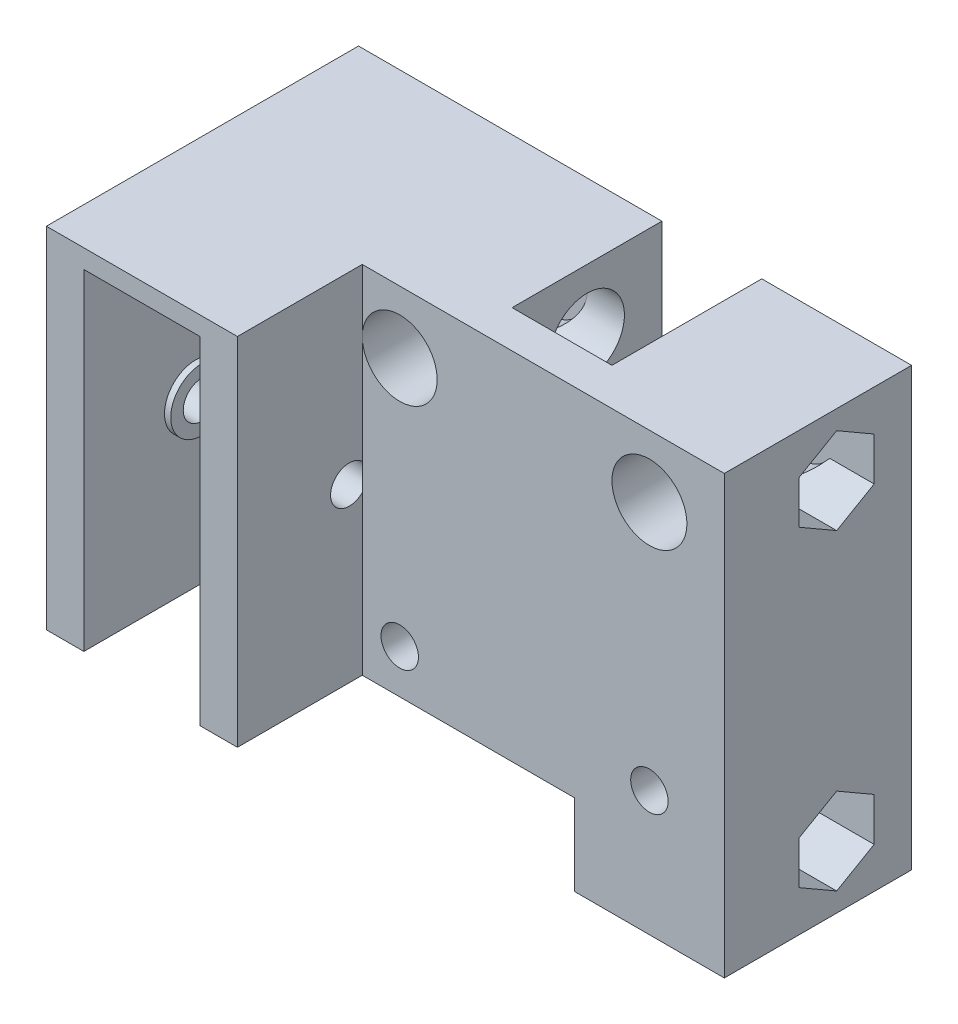
from build123d import *

# Parameters (mm, degrees)
SKETCH1_W           = 12
SKETCH1_H           = 27
SKETCH1_R           = 1.5
SKETCH1_R_2         = 3
BOSS_EXTRUDE1_DEPTH = 12
BOSS_EXTRUDE2_START = 12
SKETCH1_3_W         = 32
SKETCH1_3_H         = 27
SKETCH1_3_R         = 1.5
SKETCH1_3_R_2       = 3
BOSS_EXTRUDE2_DEPTH = 3
SKETCH2_3_R         = 1.5
CUT_EXTRUDE2_DEPTH  = 29.41214529
SKETCH3_W           = 15
SKETCH3_H           = 1.5
SKETCH3_R           = 1.5
BOSS_EXTRUDE3_DEPTH = 12
SKETCH3_4_R         = 1.5
CUT_EXTRUDE3_DEPTH  = 9
SKETCH3_5_R         = 1.5
CUT_EXTRUDE4_DEPTH  = 41.607881008
CUT_EXTRUDE9_START  = 3
SKETCH1_4_R         = 3
SKETCH1_4_R_2       = 1.5
CUT_EXTRUDE9_DEPTH  = 9
SKETCH4_W           = 3
SKETCH4_H           = 26.5
SKETCH4_W_2         = 5
SKETCH4_H_2         = 26
BOSS_EXTRUDE4_DEPTH = 5
SKETCH4_3_W         = 3
SKETCH4_3_H         = 26.5
BOSS_EXTRUDE5_DEPTH = 25
SKETCH5_W           = 3
SKETCH5_H           = 27
BOSS_EXTRUDE6_DEPTH = 10
CUT_EXTRUDE10_REACH = 56.658
SKETCH6_R           = 1.5
SKETCH7_R           = 2.5
SKETCH7_R_2         = 1.5
BOSS_EXTRUDE7_DEPTH = 0.5
BOSS_EXTRUDE8_START = 9.3
SKETCH7_2_R         = 2.5
SKETCH7_2_R_2       = 1.5
BOSS_EXTRUDE8_DEPTH = 0.5
SKETCH2_R           = 3
SKETCH2_R_2         = 1.5
CUT_EXTRUDE1_DEPTH  = 41.193158622
SKETCH8_W           = 9.3
SKETCH8_H           = 20
BOSS_EXTRUDE9_DEPTH = 1.5


with BuildPart() as part:
    # Sketch1 → Boss-Extrude1 (new body)
    with BuildSketch(Plane.XY):
        with Locations((-10, 0)):
            Rectangle(SKETCH1_W, SKETCH1_H)
        with Locations(Location((-10, 10, 0), (0, 0, 90))):
            Circle(SKETCH1_R, mode=Mode.SUBTRACT)
        with Locations(Location((-10, -10, 0), (0, 0, 90))):
            Circle(SKETCH1_R, mode=Mode.SUBTRACT)
        with Locations((10, 0)):
            Rectangle(SKETCH1_W, SKETCH1_H)
        with Locations((10, 10)):
            Circle(SKETCH1_R_2, mode=Mode.SUBTRACT)
        with Locations(Location((10, -10, 0), (0, 0, 90))):
            Circle(SKETCH1_R, mode=Mode.SUBTRACT)
        with Locations((10, 10)):
            Circle(SKETCH1_R_2)
        with Locations(Location((10, 10, 0), (0, 0, 90))):
            Circle(SKETCH1_R, mode=Mode.SUBTRACT)
        with Locations((-10, 10)):
            Circle(SKETCH1_R_2)
        with Locations(Location((-10, 10, 0), (0, 0, 90))):
            Circle(SKETCH1_R, mode=Mode.SUBTRACT)
    extrude(amount=BOSS_EXTRUDE1_DEPTH)

    # Sketch1_3 → Boss-Extrude2 (add)
    with BuildSketch(Plane.XY.offset(BOSS_EXTRUDE2_START)):
        Rectangle(SKETCH1_3_W, SKETCH1_3_H)
        with Locations(Location((-10, -10, 0), (0, 0, 90))):
            Circle(SKETCH1_3_R, mode=Mode.SUBTRACT)
        with Locations(Location((-10, 10, 0), (0, 0, 90))):
            Circle(SKETCH1_3_R_2, mode=Mode.SUBTRACT)
        with Locations(Location((10, 10, 0), (0, 0, 90))):
            Circle(SKETCH1_3_R_2, mode=Mode.SUBTRACT)
        with Locations(Location((10, -10, 0), (0, 0, 90))):
            Circle(SKETCH1_3_R, mode=Mode.SUBTRACT)
    extrude(amount=BOSS_EXTRUDE2_DEPTH)

    # Sketch2_3 → Cut-Extrude2 (cut, through all)
    with BuildSketch(Plane.ZY.offset(4)):
        with Locations((6, -15)):
            Circle(SKETCH2_3_R)
        with Locations(Location((6, 10, 0), (0, 0, 270))):
            Circle(SKETCH2_3_R)
    extrude(amount=-CUT_EXTRUDE2_DEPTH, mode=Mode.SUBTRACT)

    # Sketch3 → Boss-Extrude3 (add)
    with BuildSketch(Plane(origin=(16, 0, 0), x_dir=(0, 0, -1), z_dir=(1, 0, 0))):
        Polygon((-9, -13.5), (-15, -13.5), (-15, -20), (0, -20), (0, -13.5), (-3, -13.5), (-3, -16.732050808), (-6, -18.464101615), (-9, -16.732050808), align=None)
        with Locations((-7.5, 14.25)):
            Rectangle(SKETCH3_W, SKETCH3_H)
        Polygon((-6, -13.5), (-9, -13.5), (-9, -16.732050808), (-6, -18.464101615), (-3, -16.732050808), (-3, -13.5), align=None)
        with BuildLine():
            ThreePointArc((-4.5, -15), (-7.060660172, -16.060660172), (-6, -13.5))
            ThreePointArc((-6, -13.5), (-4.939339828, -13.939339828), (-4.5, -15))
        make_face(mode=Mode.SUBTRACT)
        with Locations((-6, -15)):
            Circle(SKETCH3_R)
    extrude(amount=-BOSS_EXTRUDE3_DEPTH)

    # Sketch3_4 → Cut-Extrude3 (cut)
    with BuildSketch(Plane(origin=(16, 0, 0), x_dir=(0, 0, -1), z_dir=(1, 0, 0))):
        Polygon((-6, 13.464101615), (-9, 11.732050808), (-9, 8.267949192), (-6, 6.535898385), (-3, 8.267949192), (-3, 11.732050808), align=None)
        Polygon((-6, -11.535898385), (-9, -13.267949192), (-9, -16.732050808), (-6, -18.464101615), (-3, -16.732050808), (-3, -13.267949192), align=None)
        with Locations(Location((-6, -15, 0), (0, 0, 90))):
            Circle(SKETCH3_4_R, mode=Mode.SUBTRACT)
    extrude(amount=-CUT_EXTRUDE3_DEPTH, mode=Mode.SUBTRACT)

    # Sketch3_5 → Cut-Extrude4 (cut, through all)
    with BuildSketch(Plane(origin=(16, 0, 0), x_dir=(0, 0, -1), z_dir=(1, 0, 0))):
        with Locations(Location((-6, -15, 0), (0, 0, 90))):
            Circle(SKETCH3_5_R)
        with Locations(Location((-6, 10, 0), (0, 0, 90))):
            Circle(SKETCH3_5_R)
    extrude(amount=-CUT_EXTRUDE4_DEPTH, mode=Mode.SUBTRACT)

    # Sketch1_4 → Cut-Extrude9 (cut)
    with BuildSketch(Plane.XY.offset(CUT_EXTRUDE9_START)):
        with Locations(Location((-10, 10, 0), (0, 0, 180))):
            Circle(SKETCH1_4_R)
        with Locations(Location((-10, 10, 0), (0, 0, 180))):
            Circle(SKETCH1_4_R_2, mode=Mode.SUBTRACT)
        with Locations(Location((10, 10, 0), (0, 0, 180))):
            Circle(SKETCH1_4_R)
        with Locations(Location((10, 10, 0), (0, 0, 180))):
            Circle(SKETCH1_4_R_2, mode=Mode.SUBTRACT)
    extrude(amount=CUT_EXTRUDE9_DEPTH, mode=Mode.SUBTRACT)

    # Sketch4 → Boss-Extrude4 (add)
    with BuildSketch(Plane.XY):
        with Locations((-26.8, 0.25)):
            Rectangle(SKETCH4_W, SKETCH4_H)
        Polygon((-25.3, -13), (-21, -13), (-21, 13), (-16, 13), (-16, 13.5), (-25.3, 13.5), align=None)
        with Locations((-18.5, 0)):
            Rectangle(SKETCH4_W_2, SKETCH4_H_2)
    extrude(amount=BOSS_EXTRUDE4_DEPTH)

    # Sketch4_3 → Boss-Extrude5 (add)
    with BuildSketch(Plane.XY):
        with Locations((-26.8, 0.25)):
            Rectangle(SKETCH4_3_W, SKETCH4_3_H)
    extrude(amount=BOSS_EXTRUDE5_DEPTH)

    # Sketch5 → Boss-Extrude6 (add)
    with BuildSketch(Plane.XY.offset(15)):
        with Locations((-14.5, 0)):
            Rectangle(SKETCH5_W, SKETCH5_H)
    extrude(amount=BOSS_EXTRUDE6_DEPTH)

    # Cut-Extrude10: up to this face of the body (flat: up to its plane)
    cut_extrude10_end = Plane(part.part.faces().sort_by_distance((-13, 0, 20))[0])
    # Sketch6 → Cut-Extrude10 (cut, up to the picked face)
    with BuildSketch(Plane.ZY.offset(28.3), mode=Mode.PRIVATE) as cut_extrude10_sk1:
        with Locations((16.04, 0.25)):
            Circle(SKETCH6_R)
    cut_extrude10_tool1 = split(extrude(cut_extrude10_sk1.sketch, amount=-CUT_EXTRUDE10_REACH, mode=Mode.PRIVATE), bisect_by=cut_extrude10_end, keep=Keep.BOTH, mode=Mode.PRIVATE)
    add(cut_extrude10_tool1.solids().sort_by(Axis((-28.3, 0.25, 16.04), (1, 0, 0)))[0], mode=Mode.SUBTRACT)

    # Sketch7 → Boss-Extrude7 (add)
    with BuildSketch(Plane(origin=(-25.3, 0, 0), x_dir=(0, 0, -1), z_dir=(1, 0, 0))):
        with Locations(Location((-16.04, 0.25, 0), (0, 0, 180))):
            Circle(SKETCH7_R)
        with Locations(Location((-16.04, 0.25, 0), (0, 0, 180))):
            Circle(SKETCH7_R_2, mode=Mode.SUBTRACT)
    extrude(amount=BOSS_EXTRUDE7_DEPTH)

    # Sketch7_2 → Boss-Extrude8 (add)
    with BuildSketch(Plane(origin=(-25.3, 0, 0), x_dir=(0, 0, -1), z_dir=(1, 0, 0)).offset(BOSS_EXTRUDE8_START)):
        with Locations(Location((-16.04, 0.25, 0), (0, 0, 180))):
            Circle(SKETCH7_2_R)
        with Locations(Location((-16.04, 0.25, 0), (0, 0, 180))):
            Circle(SKETCH7_2_R_2, mode=Mode.SUBTRACT)
    extrude(amount=-BOSS_EXTRUDE8_DEPTH)

    # Sketch2 → Cut-Extrude1 (cut, through all)
    with BuildSketch(Plane.ZY.offset(4)):
        with Locations((6, -15)):
            Circle(SKETCH2_R)
        with Locations(Location((6, -15, 0), (0, 0, 90))):
            Circle(SKETCH2_R_2, mode=Mode.SUBTRACT)
        with Locations(Location((6, 10, 0), (0, 0, 270))):
            Circle(SKETCH2_R)
        with Locations(Location((6, 10, 0), (0, 0, 90))):
            Circle(SKETCH2_R_2, mode=Mode.SUBTRACT)
        with Locations(Location((6, -15, 0), (0, 0, 90))):
            Circle(SKETCH2_R_2)
    extrude(amount=CUT_EXTRUDE1_DEPTH, mode=Mode.SUBTRACT)


with BuildPart() as cut_extrude1_kept_piece:
    # of the separate pieces the step leaves, the one the design keeps (cut_extrude1_pieces_kept)
    add(part.part.solids().sort_by_distance((-16, -13.5, 25))[0])

    # Sketch8 → Boss-Extrude9 (add)
    with BuildSketch(Plane(origin=(0, 13.5, 0), x_dir=(1, 0, 0), z_dir=(0, 1, 0))):
        Polygon((-28.3, -25), (-25.3, -25), (-25.3, -5), (-16, -5), (-16, -25), (-13, -25), (-13, -15), (4, -15), (4, -12), (-4, -12), (-4, 0), (-28.3, 0), align=None)
        with Locations((-20.65, -15)):
            Rectangle(SKETCH8_W, SKETCH8_H)
    extrude(amount=BOSS_EXTRUDE9_DEPTH)


solid = cut_extrude1_kept_piece.part
